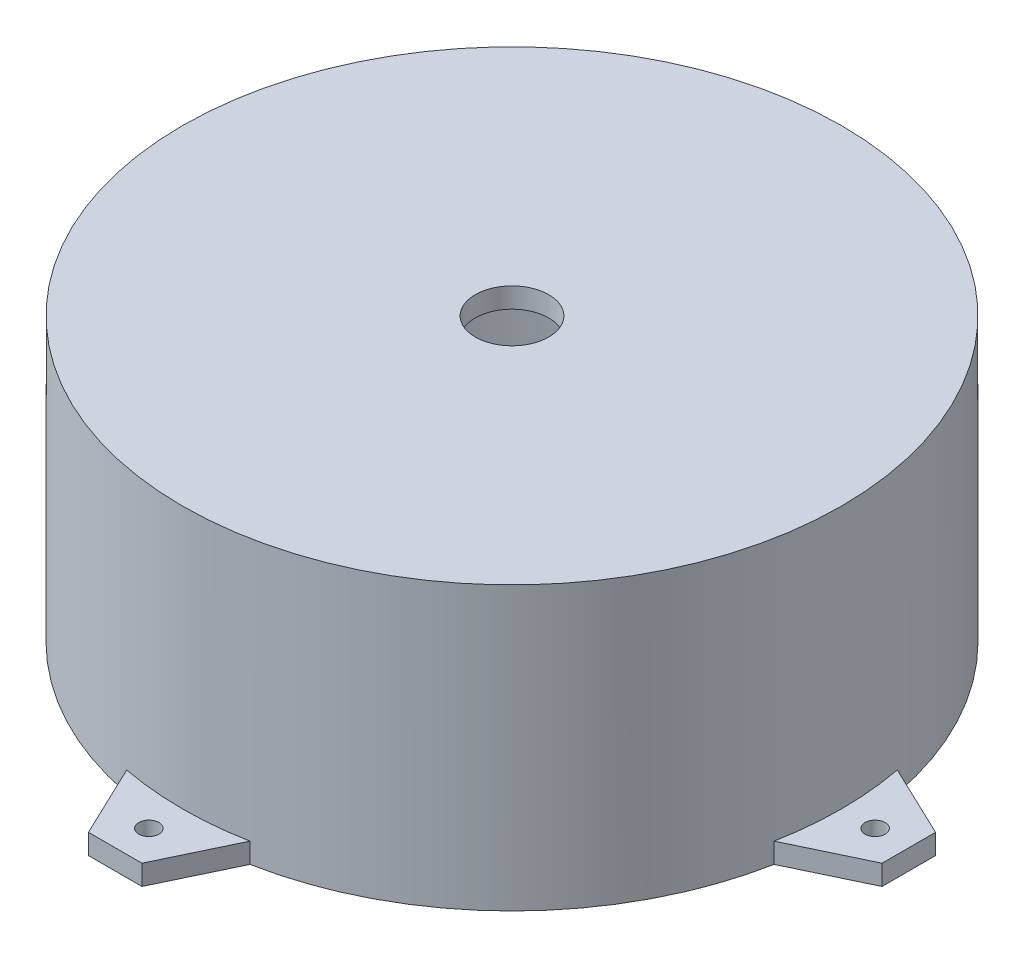
from build123d import *

# Parameters (mm, degrees)
BOSS_EXTRUDE1_DEPTH = 3
SKETCH4_R           = 1.5
CUT_EXTRUDE1_DEPTH  = 3
CIRPATTERN3_COUNT   = 4
CIRPATTERN4_COUNT   = 4
SKETCH6_R           = 5.46227
CUT_EXTRUDE2_DEPTH  = 3


with BuildPart() as part:
    # Sketch2 → Revolve3 (revolve)
    with BuildSketch(Plane.XY):
        Polygon((-5.787265578, 31.851275917), (40.212734422, 31.851275917), (40.212734422, -7.148724083), (43.212734422, -7.148724083), (43.212734422, 34.851275917), (-5.787265578, 34.851275917), align=None)
    revolve(axis=Axis((-5.787265578, 31.851275917, 0), (0, 1, 0)))

    # Sketch3 → Boss-Extrude1 (add)
    with BuildSketch(Plane(origin=(0, -7.148724083, 0), x_dir=(-1, 0, 0), z_dir=(0, -1, 0))):
        with BuildLine():
            Line((64.791542072, -3.977553736), (64.791542072, 0))
            Line((64.791542072, 0), (64.791542072, 3.977553736))
            Line((64.791542072, 3.977553736), (53.923592108, 9.15937051))
            ThreePointArc((53.923592108, 9.15937051), (54.570869381, 4.6), (54.787265578, 0))
            ThreePointArc((54.787265578, 0), (54.570869381, -4.6), (53.923592108, -9.15937051))
            Line((53.923592108, -9.15937051), (64.791542072, -3.977553736))
        make_face()
    boss_extrude1 = extrude(amount=-BOSS_EXTRUDE1_DEPTH)

    # Sketch4 → Cut-Extrude1 (cut)
    with BuildSketch(Plane.XZ.offset(7.148724083)):
        with Locations((-59.787265578, 0)):
            Circle(SKETCH4_R)
    cut_extrude1 = extrude(amount=-CUT_EXTRUDE1_DEPTH, mode=Mode.SUBTRACT)

    # CirPattern3: Boss-Extrude1 ×4 about axis
    cirpattern3_axis = Axis((-5.787265578, 0, 0), (0, 1, 0))
    for i in range(1, CIRPATTERN3_COUNT):
        add(boss_extrude1.rotate(cirpattern3_axis, i * 360 / CIRPATTERN3_COUNT))

    # CirPattern4: Cut-Extrude1 ×4 about axis
    cirpattern4_axis = Axis((-5.787265578, 0, 0), (0, 1, 0))
    for i in range(1, CIRPATTERN4_COUNT):
        add(cut_extrude1.rotate(cirpattern4_axis, i * 360 / CIRPATTERN4_COUNT), mode=Mode.SUBTRACT)

    # Sketch6 → Cut-Extrude2 (cut)
    with BuildSketch(Plane(origin=(0, 34.851275917, 0), x_dir=(1, 0, 0), z_dir=(0, 1, 0))):
        with Locations((-5.787265578, 0)):
            Circle(SKETCH6_R)
    extrude(amount=-CUT_EXTRUDE2_DEPTH, mode=Mode.SUBTRACT)


solid = part.part
